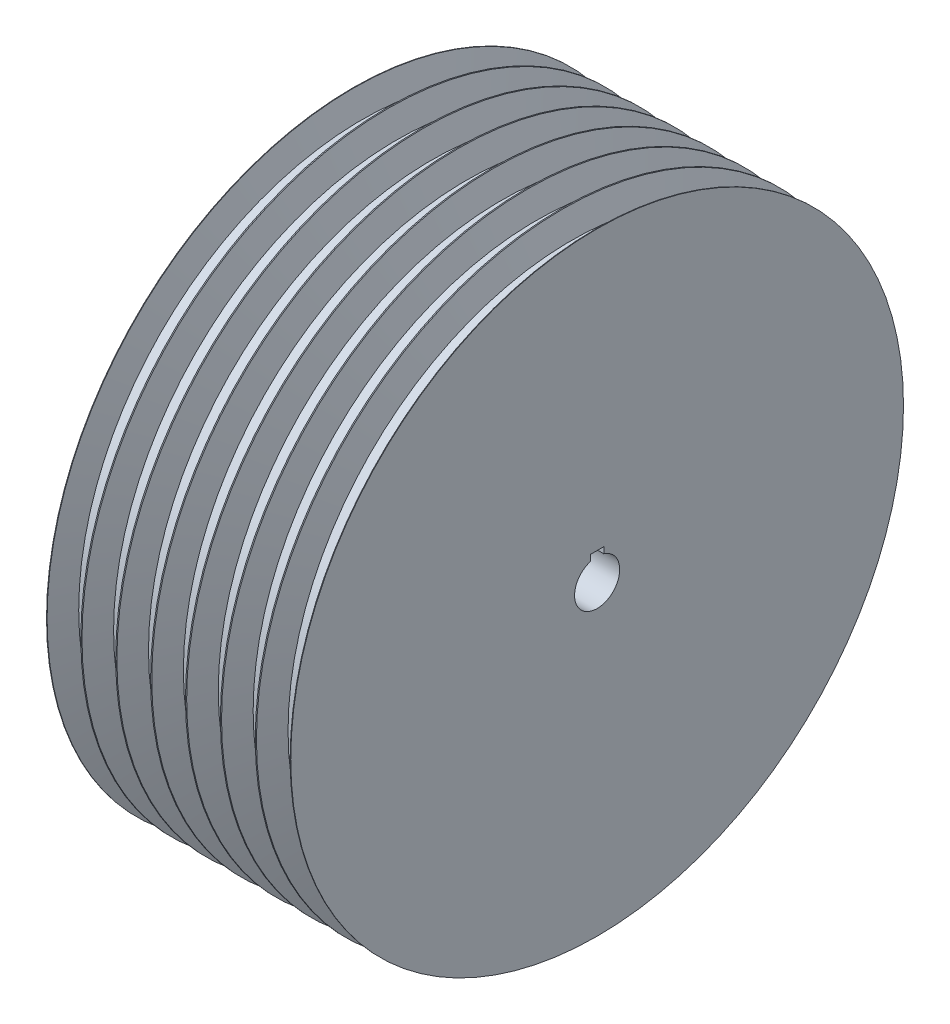
from build123d import *

# Parameters (mm, degrees)
LPATTERN1_COUNT    = 7
LPATTERN1_PITCH    = 13.1427
SKETCH2_R          = 8.5
CUT_EXTRUDE1_DEPTH = 92.999
SKETCH3_W          = 5
SKETCH3_H          = 2.3
CUT_EXTRUDE2_DEPTH = 10


with BuildPart() as part:
    # Sketch1 → Revolve1 (revolve)
    with BuildSketch(Plane.XY):
        Polygon((-3.172539855, 0), (3.172539855, 0), (6.35, 8.73), (6.5714, 8.73), (6.5714, -106.68), (-6.5714, -106.68), (-6.5714, 8.73), (-6.35, 8.73), align=None)
    revolve(axis=Axis((-6.5714, -106.68, 0), (1, 0, 0)))


with BuildPart() as lpattern1_1:
    # LPattern1: pattern copy
    add(part.part.moved(Location(Vector(1, 0, 0) * (1 * LPATTERN1_PITCH))))


with BuildPart() as lpattern1_2:
    # LPattern1: pattern copy
    add(part.part.moved(Location(Vector(1, 0, 0) * (2 * LPATTERN1_PITCH))))


with BuildPart() as lpattern1_3:
    # LPattern1: pattern copy
    add(part.part.moved(Location(Vector(1, 0, 0) * (3 * LPATTERN1_PITCH))))


with BuildPart() as lpattern1_4:
    # LPattern1: pattern copy
    add(part.part.moved(Location(Vector(1, 0, 0) * (4 * LPATTERN1_PITCH))))


with BuildPart() as lpattern1_5:
    # LPattern1: pattern copy
    add(part.part.moved(Location(Vector(1, 0, 0) * (5 * LPATTERN1_PITCH))))


with BuildPart() as lpattern1_6:
    # LPattern1: pattern copy
    add(part.part.moved(Location(Vector(1, 0, 0) * (6 * LPATTERN1_PITCH))))


with BuildPart() as cut_extrude1_tool:
    # Sketch2 → Cut-Extrude1 (new body, through all)
    with BuildSketch(Plane(origin=(85.4276, 0, 0), x_dir=(0, 0, -1), z_dir=(1, 0, 0))):
        with Locations((0, -106.68)):
            Circle(SKETCH2_R)
    extrude(amount=-CUT_EXTRUDE1_DEPTH)


with BuildPart() as part_1:
    add(part.part)

    # Cut-Extrude1: cut by cut_extrude1_tool
    add(cut_extrude1_tool.part, mode=Mode.SUBTRACT)


with BuildPart() as lpattern1_1_1:
    add(lpattern1_1.part)

    # Cut-Extrude1: cut by cut_extrude1_tool
    add(cut_extrude1_tool.part, mode=Mode.SUBTRACT)


with BuildPart() as lpattern1_2_1:
    add(lpattern1_2.part)

    # Cut-Extrude1: cut by cut_extrude1_tool
    add(cut_extrude1_tool.part, mode=Mode.SUBTRACT)


with BuildPart() as lpattern1_3_1:
    add(lpattern1_3.part)

    # Cut-Extrude1: cut by cut_extrude1_tool
    add(cut_extrude1_tool.part, mode=Mode.SUBTRACT)


with BuildPart() as lpattern1_4_1:
    add(lpattern1_4.part)

    # Cut-Extrude1: cut by cut_extrude1_tool
    add(cut_extrude1_tool.part, mode=Mode.SUBTRACT)


with BuildPart() as lpattern1_5_1:
    add(lpattern1_5.part)

    # Cut-Extrude1: cut by cut_extrude1_tool
    add(cut_extrude1_tool.part, mode=Mode.SUBTRACT)


with BuildPart() as lpattern1_6_1:
    add(lpattern1_6.part)

    # Cut-Extrude1: cut by cut_extrude1_tool
    add(cut_extrude1_tool.part, mode=Mode.SUBTRACT)

    # Sketch3 → Cut-Extrude2 (cut)
    with BuildSketch(Plane(origin=(85.4276, 0, 0), x_dir=(0, 0, -1), z_dir=(1, 0, 0))):
        with Locations((0, -97.405961595)):
            Rectangle(SKETCH3_W, SKETCH3_H)
    extrude(amount=-CUT_EXTRUDE2_DEPTH, mode=Mode.SUBTRACT)


solid = Compound([part_1.part, lpattern1_1_1.part, lpattern1_2_1.part, lpattern1_3_1.part, lpattern1_4_1.part, lpattern1_5_1.part, lpattern1_6_1.part])
